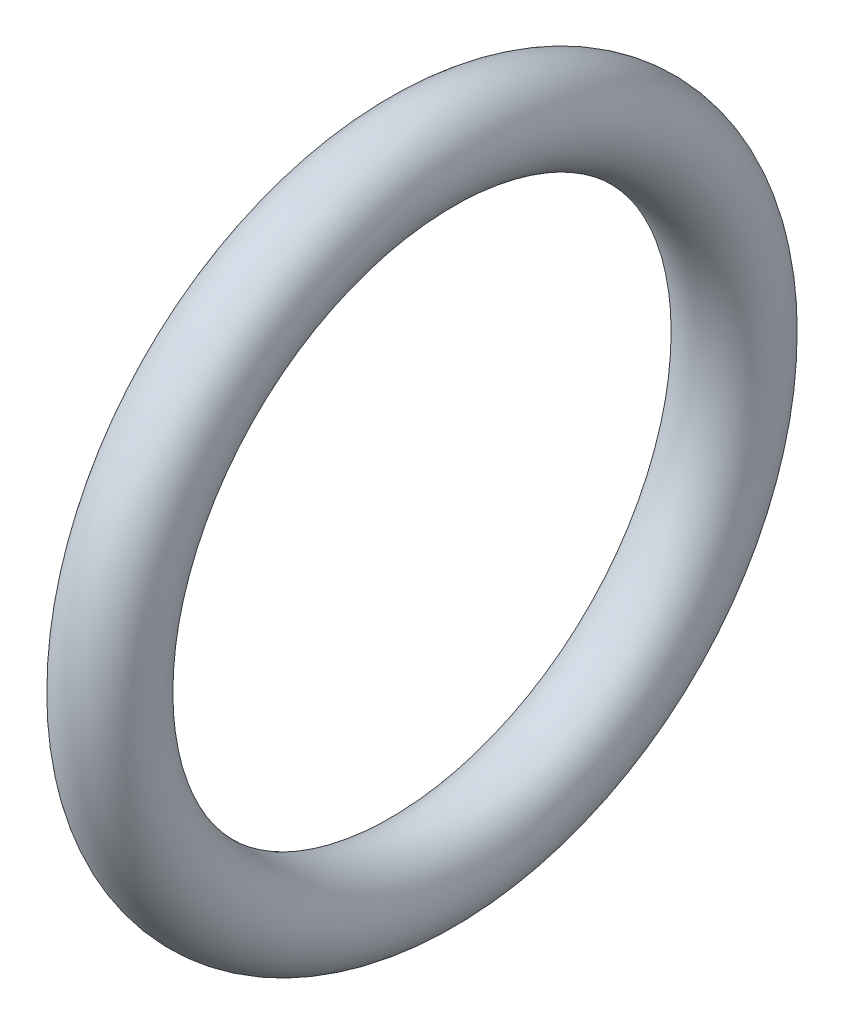
from build123d import *

# Parameters (mm, degrees)
SKETCH1_R = 0.79375


with BuildPart() as part:
    # Sketch1 → Revolve2 (revolve)
    with BuildSketch(Plane.XY):
        with Locations((0, 5.55625)):
            Circle(SKETCH1_R)
    revolve(axis=Axis((-3.180246236, 0, 0), (1, 0, 0)))


solid = part.part
